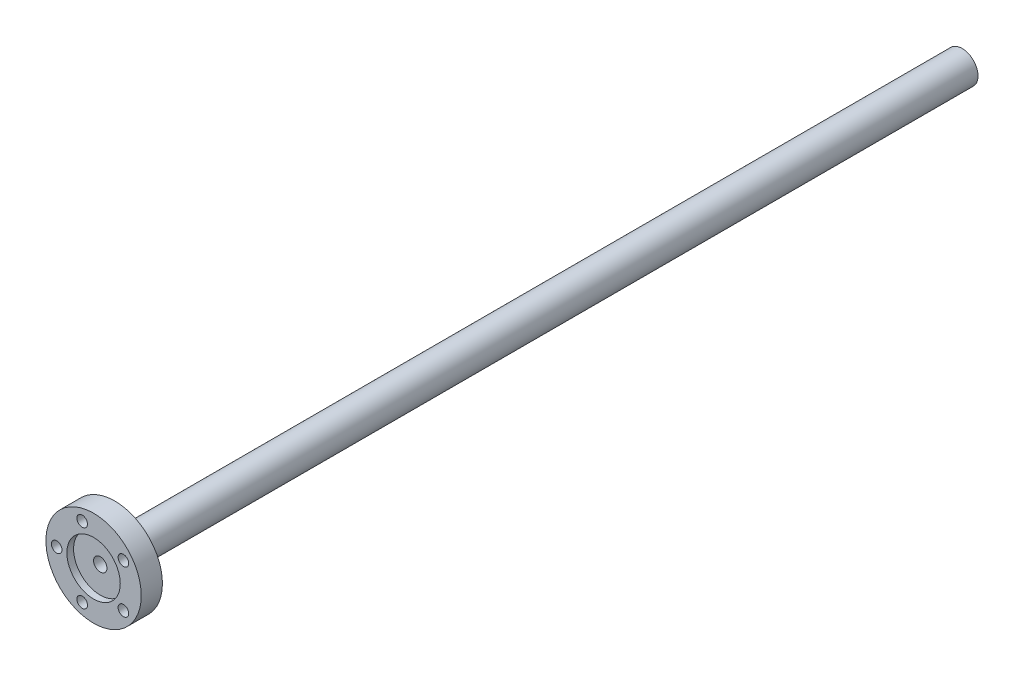
from build123d import *

# Parameters (mm, degrees)
SKETCH1_W           = 14.2875
SKETCH1_H           = 6.35
SKETCH2_R           = 4.7625
BOSS_EXTRUDE1_DEPTH = 254
CUT_EXTRUDE1_DEPTH  = 32.004
HOLE1_D             = 2.1844
HOLE1_DEPTH         = 260.35
HOLE1_CBORE_D       = 3.175
HOLE1_CBORE_DEPTH   = 4.7625
HOLE2_D             = 2.1844
HOLE2_DEPTH         = 260.35
HOLE2_CBORE_D       = 3.175
HOLE2_CBORE_DEPTH   = 4.7625
HOLE3_D             = 2.1844
HOLE3_DEPTH         = 260.35
HOLE3_CBORE_D       = 3.175
HOLE3_CBORE_DEPTH   = 4.7625
HOLE4_D             = 2.1844
HOLE4_DEPTH         = 260.35
HOLE4_CBORE_D       = 3.175
HOLE4_CBORE_DEPTH   = 4.7625
HOLE5_D             = 4
HOLE5_DEPTH         = 5
HOLE5_CBORE_D       = 16
HOLE5_CBORE_DEPTH   = 2
FILLET1_R           = 0.7874


with BuildPart() as part:
    # Sketch1 → Revolve1 (revolve)
    with BuildSketch(Plane(origin=(0, 0, 0), x_dir=(1, 0, 0), z_dir=(0, 1, 0))):
        with Locations((7.14375, 3.175)):
            Rectangle(SKETCH1_W, SKETCH1_H)
    revolve(axis=Axis((0, 0, -6.35), (0, 0, 1)))

    # Sketch2 → Boss-Extrude1 (add)
    with BuildSketch(Plane(origin=(0, 0, -6.35), x_dir=(-1, 0, 0), z_dir=(0, 0, -1))):
        Circle(SKETCH2_R)
    extrude(amount=BOSS_EXTRUDE1_DEPTH)

    # Sketch3 → Cut-Extrude1 (cut)
    with BuildSketch(Plane(origin=(0, 0, -260.35), x_dir=(-1, 0, 0), z_dir=(0, 0, -1))):
        with BuildLine():
            Line((1, -4.656329697), (1, -3.783346351))
            Line((1, -3.783346351), (-1, -3.783346351))
            Line((-1, -3.783346351), (-1, -4.656329697))
            ThreePointArc((-1, -4.656329697), (0, -4.7625), (1, -4.656329697))
        make_face()
    extrude(amount=-CUT_EXTRUDE1_DEPTH, mode=Mode.SUBTRACT)

    # Sketch4 → Cut-Revolve1 (revolve, cut)
    with BuildSketch(Plane.XZ, mode=Mode.PRIVATE) as cut_revolve1_sk:
        Polygon((-9.4725, 0), (-11.06, 0), (-11.06, -6.35), (-9.5233, -6.35), (-9.5233, -4.7625), (-9.4725, -4.7625), align=None)
    revolve(cut_revolve1_sk.sketch.rotate(Axis((-11.06, 0, 0), (0, 0, -1)), 180), axis=Axis((-11.06, 0, 0), (0, 0, -1)), mode=Mode.SUBTRACT)  # turned: the seam where the file's is

    # Hole1
    with Locations(Plane.XY):
        with Locations((-3.417727958, -10.51868507)):
            CounterBoreHole(HOLE1_D / 2, HOLE1_CBORE_D / 2, HOLE1_CBORE_DEPTH, depth=HOLE1_DEPTH)

    # Hole2
    with Locations(Plane.XY):
        with Locations((8.947727958, -6.50090489)):
            CounterBoreHole(HOLE2_D / 2, HOLE2_CBORE_D / 2, HOLE2_CBORE_DEPTH, depth=HOLE2_DEPTH)

    # Hole3
    with Locations(Plane.XY):
        with Locations((8.947727958, 6.50090489)):
            CounterBoreHole(HOLE3_D / 2, HOLE3_CBORE_D / 2, HOLE3_CBORE_DEPTH, depth=HOLE3_DEPTH)

    # Hole4
    with Locations(Plane.XY):
        with Locations((-3.417727958, 10.51868507)):
            CounterBoreHole(HOLE4_D / 2, HOLE4_CBORE_D / 2, HOLE4_CBORE_DEPTH, depth=HOLE4_DEPTH)

    # Hole5
    with Locations(Plane.XY):
        with Locations((0, 0)):
            CounterBoreHole(HOLE5_D / 2, HOLE5_CBORE_D / 2, HOLE5_CBORE_DEPTH, depth=HOLE5_DEPTH)

    # Fillet1
    fillet1_edges = [part.edges().sort_by_distance(p)[0] for p in [
        (4.7625, 0, -6.35),
    ]]
    fillet(fillet1_edges, radius=FILLET1_R)


solid = part.part
